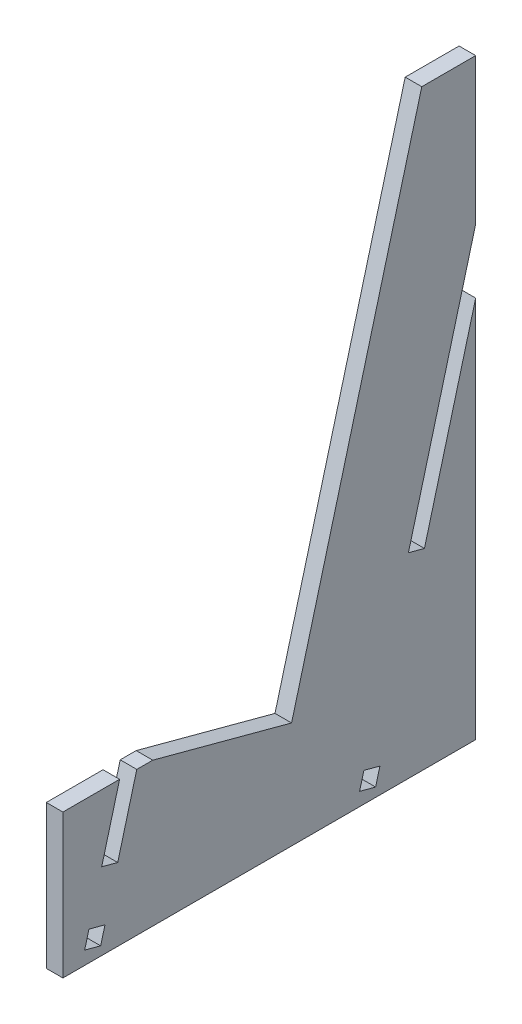
from build123d import *

# Parameters (mm, degrees)
BOSS_EXTRUDE1_DEPTH = 2.93
CUT_EXTRUDE4_DEPTH  = 3.93
CUT_EXTRUDE6_DEPTH  = 3.93
CUT_EXTRUDE7_DEPTH  = 3.93
CUT_EXTRUDE9_DEPTH  = 3.93


with BuildPart() as part:
    # Sketch1 → Boss-Extrude1 (new body)
    with BuildSketch(Plane(origin=(0, 0, 0), x_dir=(0, 0, -1), z_dir=(1, 0, 0))):
        Polygon((0, 0), (0, 104.696802211), (-9.525, 104.696802211), (-32.53401311, 18.825996254), (-57.068529097, 25.4), (-72.943529097, 25.4), (-72.943529097, 0), align=None)
    extrude(amount=BOSS_EXTRUDE1_DEPTH)

    # Sketch5 → Cut-Extrude4 (cut, through all)
    with BuildSketch(Plane(origin=(2.93, 0, 0), x_dir=(0, 0, -1), z_dir=(1, 0, 0))):
        Polygon((0, 67.5876455), (0, 78.908296184), (-11.885190186, 34.552162552), (-9.055027515, 33.79382275), align=None)
    extrude(amount=-CUT_EXTRUDE4_DEPTH, mode=Mode.SUBTRACT)

    # Sketch7 → Cut-Extrude6 (cut, through all)
    with BuildSketch(Plane.ZY):
        Polygon((63.256615243, 12.832490583), (66.086777914, 13.590830386), (62.719323915, 26.158339802), (59.889161244, 25.4), align=None)
    extrude(amount=-CUT_EXTRUDE6_DEPTH, mode=Mode.SUBTRACT)

    # Sketch9 → Cut-Extrude7 (cut, through all)
    with BuildSketch(Plane.ZY):
        Polygon((65.511361587, 4.417662671), (68.341524258, 5.176002473), (69.09986406, 2.345839802), (66.269701389, 1.5875), align=None)
    extrude(amount=-CUT_EXTRUDE7_DEPTH, mode=Mode.SUBTRACT)

    # Sketch11 → Cut-Extrude9 (cut, through all)
    with BuildSketch(Plane.ZY):
        Polygon((17.683407431, 1.592270516), (20.513570102, 2.350610318), (19.7552303, 5.180772989), (16.925067629, 4.422433187), align=None)
    extrude(amount=-CUT_EXTRUDE9_DEPTH, mode=Mode.SUBTRACT)


solid = part.part
